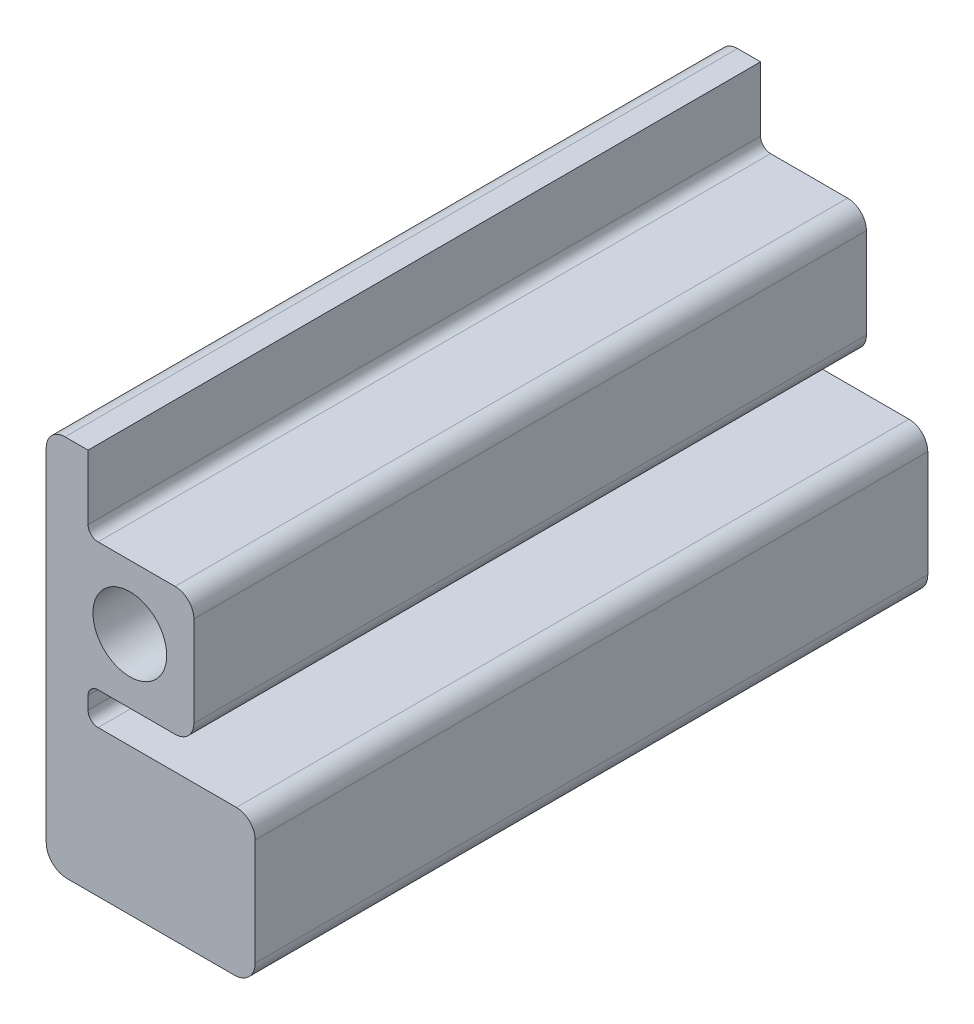
from build123d import *

# Parameters (mm, degrees)
SKETCH1_R           = 11.2
BOSS_EXTRUDE1_DEPTH = 204.313708212
CUT_EXTRUDE1_DEPTH  = 236.982


with BuildPart() as part:
    # Sketch1 → Boss-Extrude1 (new body)
    with BuildSketch(Plane.XY):
        with BuildLine():
            Line((-25.4, -67.479999962), (-25.4, 36.365))
            ThreePointArc((-25.4, 36.365), (-23.726115254, 40.406115254), (-19.685, 42.08))
            Line((-19.685, 42.08), (32.385, 42.08))
            ThreePointArc((32.385, 42.08), (36.426115254, 40.406115254), (38.1, 36.365))
            Line((38.1, 36.365), (38.1, 35.095))
            ThreePointArc((38.1, 35.095), (36.426115254, 31.053884746), (32.385, 29.38))
            Line((32.385, 29.38), (-9.652, 29.38))
            ThreePointArc((-9.652, 29.38), (-11.807261469, 28.487261469), (-12.7, 26.332))
            Line((-12.7, 26.332), (-12.7, 22.503))
            ThreePointArc((-12.7, 22.503), (-11.807261469, 20.347738531), (-9.652, 19.455))
            Line((-9.652, 19.455), (0, 19.455))
            Line((0, 19.455), (13.74, 19.455))
            ThreePointArc((13.74, 19.455), (17.781115254, 17.781115254), (19.455, 13.74))
            Line((19.455, 13.74), (19.455, 0))
            Line((19.455, 0), (19.455, -13.74))
            ThreePointArc((19.455, -13.74), (17.781115254, -17.781115254), (13.74, -19.455))
            Line((13.74, -19.455), (0, -19.455))
            Line((0, -19.455), (-9.652, -19.455))
            ThreePointArc((-9.652, -19.455), (-11.807261469, -20.347738531), (-12.7, -22.503))
            Line((-12.7, -22.503), (-12.7, -26.331999962))
            ThreePointArc((-12.7, -26.331999962), (-11.807261469, -28.487261431), (-9.652, -29.379999962))
            Line((-9.652, -29.379999962), (32.385, -29.379999962))
            ThreePointArc((32.385, -29.379999962), (36.426115254, -31.053884708), (38.1, -35.094999962))
            Line((38.1, -35.094999962), (38.1, -67.479999962))
            ThreePointArc((38.1, -67.479999962), (36.240128061, -71.970128023), (31.75, -73.829999962))
            Line((31.75, -73.829999962), (-19.05, -73.829999962))
            ThreePointArc((-19.05, -73.829999962), (-23.540128061, -71.970128023), (-25.4, -67.479999962))
        make_face()
        Circle(SKETCH1_R, mode=Mode.SUBTRACT)
    extrude(amount=BOSS_EXTRUDE1_DEPTH)

    # Sketch2 → Cut-Extrude1 (cut)
    with BuildSketch(Plane.XY.offset(204.313708212)):
        with BuildLine():
            ThreePointArc((32.385, 29.38), (36.426115254, 31.053884746), (38.1, 35.095))
            Line((38.1, 35.095), (38.1, 36.365))
            ThreePointArc((38.1, 36.365), (36.426115254, 40.406115254), (32.385, 42.08))
            Line((32.385, 42.08), (19.455, 42.08))
            Line((19.455, 42.08), (19.455, 29.38))
            Line((19.455, 29.38), (32.385, 29.38))
        make_face()
        with BuildLine():
            Line((-9.652, 29.38), (19.455, 29.38))
            Line((19.455, 29.38), (19.455, 42.08))
            Line((19.455, 42.08), (-12.7, 42.08))
            Line((-12.7, 42.08), (-12.7, 26.332))
            ThreePointArc((-12.7, 26.332), (-11.807261469, 28.487261469), (-9.652, 29.38))
        make_face()
        with BuildLine():
            Line((19.455, 13.74), (19.455, -13.74))
            Line((19.455, -13.74), (38.1, -13.74))
            Line((38.1, -13.74), (38.1, 35.095))
            ThreePointArc((38.1, 35.095), (36.426115254, 31.053884746), (32.385, 29.38))
            Line((32.385, 29.38), (19.455, 29.38))
            Line((19.455, 29.38), (19.455, 22.503))
            Line((19.455, 22.503), (19.455, 13.74))
        make_face()
        with BuildLine():
            ThreePointArc((32.385, 42.08), (36.426115254, 40.406115254), (38.1, 36.365))
            Line((38.1, 36.365), (38.1, 42.08))
            Line((38.1, 42.08), (32.385, 42.08))
        make_face()
        with BuildLine():
            Line((-12.7, 22.503), (19.455, 22.503))
            Line((19.455, 22.503), (19.455, 29.38))
            Line((19.455, 29.38), (-9.652, 29.38))
            ThreePointArc((-9.652, 29.38), (-11.807261469, 28.487261469), (-12.7, 26.332))
            Line((-12.7, 26.332), (-12.7, 22.503))
        make_face()
    extrude(amount=-CUT_EXTRUDE1_DEPTH, mode=Mode.SUBTRACT)


solid = part.part
